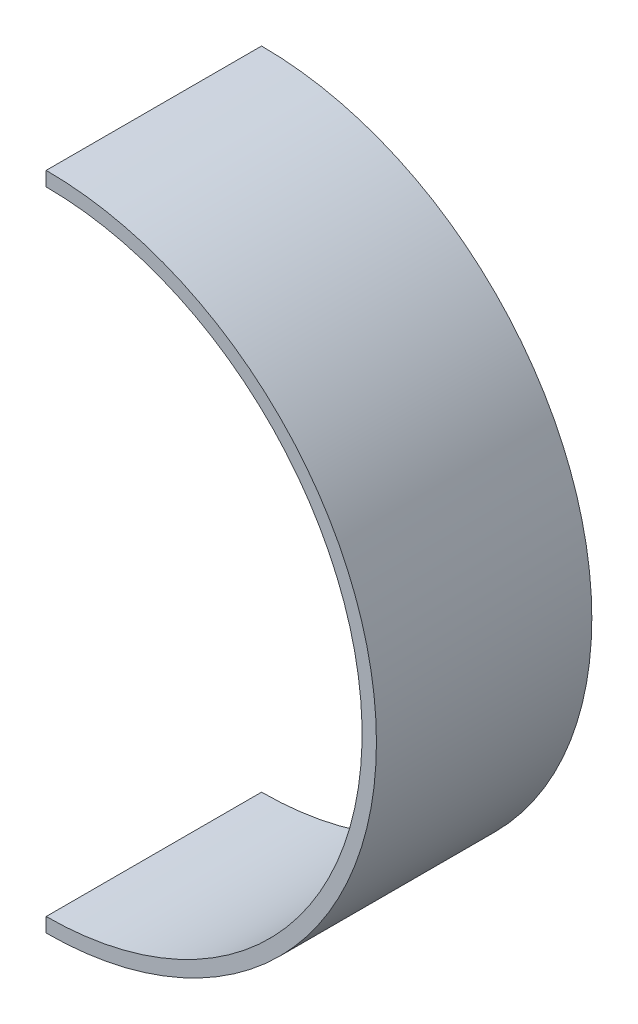
from build123d import *

# Parameters (mm, degrees)
SKETCH_1_R          = 1
EXTRUDE_1_DEPTH     = 15
EXTRUDE_2_DEPTH     = 15
CUT_EXTRUDE_1_DEPTH = 16


with BuildPart() as part:
    # ｽｹｯﾁ1 → ﾎﾞｽ - 押し出し1 (new body)
    with BuildSketch(Plane.XY):
        Circle(SKETCH_1_R)
    extrude(amount=EXTRUDE_1_DEPTH)

    # ｽｹｯﾁ2 → ﾎﾞｽ - 押し出し2 (add)
    with BuildSketch(Plane.XY.offset(15)):
        with BuildLine():
            Line((0, -44.5), (0, -45.5))
            ThreePointArc((0, -45.5), (23, -22.5), (0, 0.5))
            Line((0, 0.5), (0, -0.5))
            ThreePointArc((0, -0.5), (22, -22.5), (0, -44.5))
        make_face()
    extrude(amount=-EXTRUDE_2_DEPTH)

    # ｽｹｯﾁ6 → ｶｯﾄ - 押し出し1 (cut, through all)
    with BuildSketch(Plane.XY.offset(15)):
        with BuildLine():
            Line((0, 0.5), (0, -0.5))
            ThreePointArc((0, -0.5), (0.428174419, -0.504167061), (0.856186636, -0.516666667))
            Line((0.856186636, -0.516666667), (0.856186636, -1.684394884))
            Line((0.856186636, -1.684394884), (-3.351649942, -1.684394884))
            Line((-3.351649942, -1.684394884), (-3.351649942, 1.730475854))
            Line((-3.351649942, 1.730475854), (0.875436399, 1.730475854))
            Line((0.875436399, 1.730475854), (0.875436399, 0.483333333))
            ThreePointArc((0.875436399, 0.483333333), (0.437797518, 0.495832956), (0, 0.5))
        make_face()
    extrude(amount=-CUT_EXTRUDE_1_DEPTH, mode=Mode.SUBTRACT)


solid = part.part
